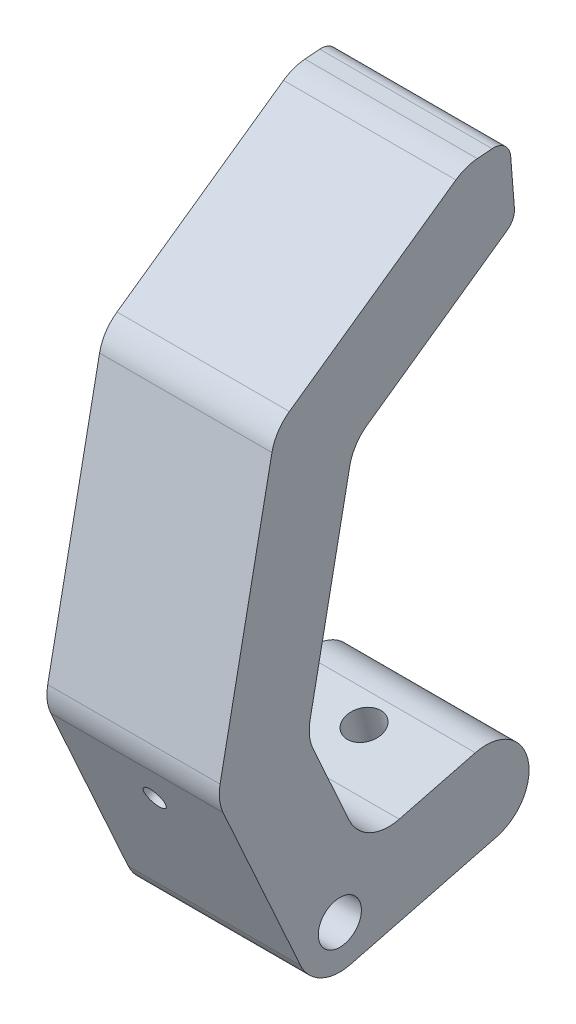
from build123d import *

# Parameters (mm, degrees)
SKETCH1_R           = 3.175
BOSS_EXTRUDE1_DEPTH = 25.4
FILLET1_R           = 6.35
CUT_EXTRUDE1_REACH  = 97.723
SKETCH2_R           = 2.54
CUT_EXTRUDE2_REACH  = 69.917
SKETCH3_R           = 1.5875
FILLET2_R           = 2.54


with BuildPart() as part:
    # Sketch1 → Boss-Extrude1 (new body)
    with BuildSketch(Plane(origin=(0, 0, 0), x_dir=(0, 0, -1), z_dir=(1, 0, 0))):
        with BuildLine():
            Line((-9.510223779, 67.442100456), (18.518782335, 87.194732923))
            Line((18.518782335, 87.194732923), (24.971703957, 87.705940953))
            Line((24.971703957, 87.705940953), (25.834610798, 76.813564689))
            Line((25.834610798, 76.813564689), (1.957775741, 59.987054843))
            Line((1.957775741, 59.987054843), (-4.791410802, 25.984772629))
            Line((-4.791410802, 25.984772629), (3.587814077, 7.472662593))
            Line((3.587814077, 7.472662593), (19.957119618, 11.661325034))
            ThreePointArc((19.957119618, 11.661325034), (27.683063897, 7.083685359), (23.105424222, -0.64225892))
            Line((23.105424222, -0.64225892), (-3.587814077, -7.472662593))
            Line((-3.587814077, -7.472662593), (-18.041777156, 24.460285718))
            Line((-18.041777156, 24.460285718), (-9.510223779, 67.442100456))
        make_face()
        Circle(SKETCH1_R, mode=Mode.SUBTRACT)
    extrude(amount=BOSS_EXTRUDE1_DEPTH)

    # Fillet1
    fillet1_edges = [part.edges().sort_by_distance(p)[0] for p in [
        (12.7, 67.442100456, 9.510223779),
        (12.7, 87.194732923, -18.518782335),
        (12.7, 59.987054843, -1.957775741),
        (12.7, 25.984772629, 4.791410802),
        (12.7, 7.472662593, -3.587814077),
        (12.7, -7.472662593, 3.587814077),
        (12.7, 24.460285718, 18.041777156),
    ]]
    fillet(fillet1_edges, radius=FILLET1_R)

    # Sketch2 → Cut-Extrude1 (cut, up to next)
    with BuildSketch(Plane(origin=(0, -6.151791977, -1.574152302), x_dir=(1, 0, 0), z_dir=(0, -0.968786138, -0.247898)), mode=Mode.PRIVATE) as cut_extrude1_sk1:
        with Locations((12.7, -18.415)):
            Circle(SKETCH2_R)
    cut_extrude1_tool1 = extrude(cut_extrude1_sk1.sketch, amount=-CUT_EXTRUDE1_REACH, mode=Mode.PRIVATE) & part.part
    add(cut_extrude1_tool1.solids().sort_by_distance((12.7, -1.58675, -19.414349))[0], mode=Mode.SUBTRACT)

    # Sketch3 → Cut-Extrude2 (cut, up to next)
    with BuildSketch(Plane(origin=(0, -2.618484858, 5.784983755), x_dir=(1, 0, 0), z_dir=(0, -0.41235982, 0.911021064)), mode=Mode.PRIVATE) as cut_extrude2_sk1:
        with Locations((12.7, 21.336)):
            Circle(SKETCH3_R)
    cut_extrude2_tool1 = extrude(cut_extrude2_sk1.sketch, amount=-CUT_EXTRUDE2_REACH, mode=Mode.PRIVATE) & part.part
    add(cut_extrude2_tool1.solids().sort_by_distance((12.7, 16.819061, 14.583093))[0], mode=Mode.SUBTRACT)

    # Fillet2
    fillet2_edges = [part.edges().sort_by_distance(p)[0] for p in [
        (12.7, 87.705940953, -24.971703957),
        (12.7, 76.813564689, -25.834610798),
    ]]
    fillet(fillet2_edges, radius=FILLET2_R)


solid = part.part
